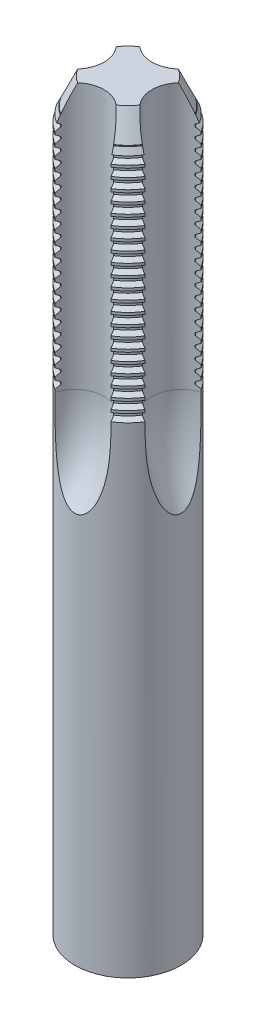
from build123d import *

# Parameters (mm, degrees)
SKETCH_1_W               = 10
SKETCH_1_H               = 140
PATTERN_CIRCULAR_2_COUNT = 4


with BuildPart() as part:
    # 草图1 → 旋转1 (revolve)
    with BuildSketch(Plane.XY):
        with Locations((5, -10)):
            Rectangle(SKETCH_1_W, SKETCH_1_H)
    revolve(axis=Axis((0, 64.716258352, 0), (0, -1, 0)))

    # 切除-扫描3: sweep along a path in 草图6
    with BuildLine(Plane.XY) as sweep_3_path:
        Line((-6.75, 60), (-6.75, 10))
        ThreePointArc((-6.75, 10), (-8.37057021, 1.203995396), (-13.019469103, -6.436926268))
    # 草图3 → 切除-扫描3 (sweep, cut)
    with BuildSketch(Plane(origin=(0, 60, 0), x_dir=(1, 0, 0), z_dir=(0, 1, 0))):
        with BuildLine():
            ThreePointArc((-9, 5.408326913), (-10.5, 0), (-9, -5.408326913))
            ThreePointArc((-9, -5.408326913), (-4.5, 0), (-9, 5.408326913))
        make_face()
    sweep_3 = sweep(path=sweep_3_path.line, mode=Mode.SUBTRACT)

    # 阵列(圆周)2: 切除-扫描3 ×4 about axis
    pattern_circular_2_axis = Axis((0, 0, 0), (0, 1, 0))
    for i in range(1, PATTERN_CIRCULAR_2_COUNT):
        add(sweep_3.rotate(pattern_circular_2_axis, i * 360 / PATTERN_CIRCULAR_2_COUNT), mode=Mode.SUBTRACT)

    # 草图8 → 切除-旋转5 (revolve, cut)
    with BuildSketch(Plane.XY):
        Polygon((-10, 60), (-9.150342411, 59.47266521), (-9.150342411, 59.02733479), (-10, 58.5), align=None)
        Polygon((-10, 58), (-9.150342411, 57.47266521), (-9.150342411, 57.02733479), (-10, 56.5), align=None)
        Polygon((-10, 56), (-9.150342411, 55.47266521), (-9.150342411, 55.02733479), (-10, 54.5), align=None)
        Polygon((-10, 54), (-9.150342411, 53.47266521), (-9.150342411, 53.02733479), (-10, 52.5), align=None)
        Polygon((-10, 52), (-9.150342411, 51.47266521), (-9.150342411, 51.02733479), (-10, 50.5), align=None)
        Polygon((-10, 50), (-9.150342411, 49.47266521), (-9.150342411, 49.02733479), (-10, 48.5), align=None)
        Polygon((-10, 48), (-9.150342411, 47.47266521), (-9.150342411, 47.02733479), (-10, 46.5), align=None)
        Polygon((-10, 46), (-9.150342411, 45.47266521), (-9.150342411, 45.02733479), (-10, 44.5), align=None)
        Polygon((-10, 44), (-9.150342411, 43.47266521), (-9.150342411, 43.02733479), (-10, 42.5), align=None)
        Polygon((-10, 42), (-9.150342411, 41.47266521), (-9.150342411, 41.02733479), (-10, 40.5), align=None)
        Polygon((-10, 40), (-9.150342411, 39.47266521), (-9.150342411, 39.02733479), (-10, 38.5), align=None)
        Polygon((-10, 38), (-9.150342411, 37.47266521), (-9.150342411, 37.02733479), (-10, 36.5), align=None)
        Polygon((-10, 36), (-9.150342411, 35.47266521), (-9.150342411, 35.02733479), (-10, 34.5), align=None)
        Polygon((-10, 34), (-9.150342411, 33.47266521), (-9.150342411, 33.02733479), (-10, 32.5), align=None)
        Polygon((-10, 32), (-9.150342411, 31.47266521), (-9.150342411, 31.02733479), (-10, 30.5), align=None)
        Polygon((-10, 30), (-9.150342411, 29.47266521), (-9.150342411, 29.02733479), (-10, 28.5), align=None)
        Polygon((-10, 28), (-9.150342411, 27.47266521), (-9.150342411, 27.02733479), (-10, 26.5), align=None)
        Polygon((-10, 26), (-9.150342411, 25.47266521), (-9.150342411, 25.02733479), (-10, 24.5), align=None)
        Polygon((-10, 24), (-9.150342411, 23.47266521), (-9.150342411, 23.02733479), (-10, 22.5), align=None)
        Polygon((-10, 22), (-9.150342411, 21.47266521), (-9.150342411, 21.02733479), (-10, 20.5), align=None)
        Polygon((-10, 20), (-9.150342411, 19.47266521), (-9.150342411, 19.02733479), (-10, 18.5), align=None)
        Polygon((-10, 18), (-9.150342411, 17.47266521), (-9.150342411, 17.02733479), (-10, 16.5), align=None)
        Polygon((-10, 16), (-9.150342411, 15.47266521), (-9.150342411, 15.02733479), (-10, 14.5), align=None)
        Polygon((-10, 14), (-9.150342411, 13.47266521), (-9.150342411, 13.02733479), (-10, 12.5), align=None)
        Polygon((-10, 12), (-9.150342411, 11.47266521), (-9.150342411, 11.02733479), (-10, 10.5), align=None)
    revolve(axis=Axis((0, 64.716258352, 0), (0, 1, 0)), mode=Mode.SUBTRACT)

    # 草图10 → 切除-旋转7 (revolve, cut)
    with BuildSketch(Plane.XY):
        Polygon((-10, 53.309103864), (-6.887721622, 60), (-10, 60), align=None)
    revolve(axis=Axis((0, 60, 0), (0, -1, 0)), mode=Mode.SUBTRACT)


solid = part.part
